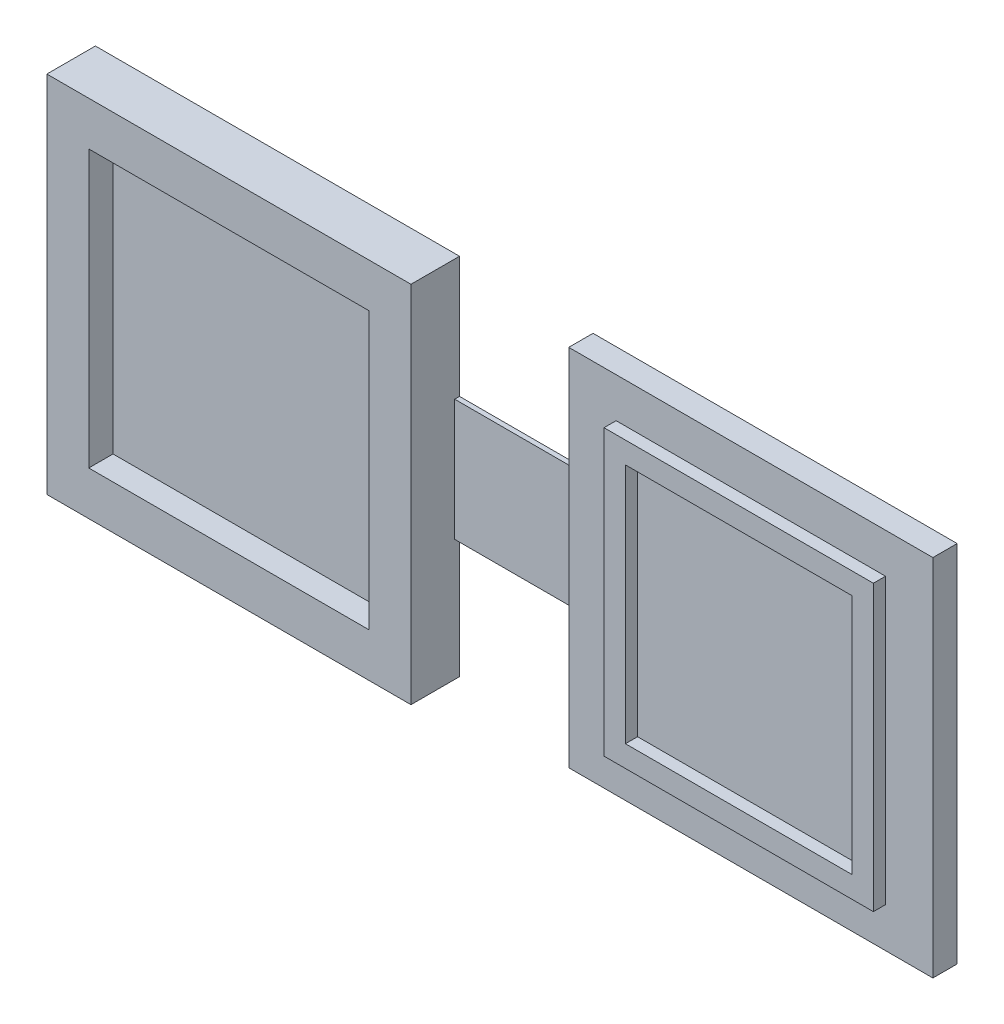
from build123d import *

# Parameters (mm, degrees)
SKETCH1_W             = 30
SKETCH1_H             = 30
BOSS_EXTRUDE1_DEPTH   = 2
BOSS_EXTRUDE1_2_DEPTH = 2
SKETCH1_3_W           = 30
SKETCH1_3_H           = 30
SKETCH1_3_W_2         = 23.094824398
SKETCH1_3_H_2         = 22.76684371
BOSS_EXTRUDE2_DEPTH   = 4
SKETCH1_4_W           = 22.194379656
SKETCH1_4_H           = 23.434004946
SKETCH1_4_W_2         = 18.65884575
SKETCH1_4_H_2         = 19.89847104
BOSS_EXTRUDE3_DEPTH   = 3
SKETCH1_5_W           = 11
SKETCH1_5_H           = 10
BOSS_EXTRUDE4_DEPTH   = 0.4


with BuildPart() as part:
    # Sketch1 → Boss-Extrude1 (new body)
    with BuildSketch(Plane.XY):
        with Locations((-43.876243767, 6.913043478)):
            Rectangle(SKETCH1_W, SKETCH1_H)
    extrude(amount=BOSS_EXTRUDE1_DEPTH)

    # Sketch1_3 → Boss-Extrude2 (add)
    with BuildSketch(Plane.XY):
        with Locations((-43.876243767, 6.913043478)):
            Rectangle(SKETCH1_3_W, SKETCH1_3_H)
        with Locations((-43.876243767, 6.913043478)):
            Rectangle(SKETCH1_3_W_2, SKETCH1_3_H_2, mode=Mode.SUBTRACT)
    extrude(amount=BOSS_EXTRUDE2_DEPTH)



with BuildPart() as body_2:
    # Sketch1 → Boss-Extrude1 2 (new body)
    with BuildSketch(Plane.XY):
        with Locations((-2.876243767, 6.913043478)):
            Rectangle(SKETCH1_W, SKETCH1_H)
    extrude(amount=BOSS_EXTRUDE1_2_DEPTH)

    # Sketch1_4 → Boss-Extrude3 (add)
    with BuildSketch(Plane.XY):
        with Locations((-2.876243767, 6.913043478)):
            Rectangle(SKETCH1_4_W, SKETCH1_4_H)
        with Locations((-2.876243767, 6.913043478)):
            Rectangle(SKETCH1_4_W_2, SKETCH1_4_H_2, mode=Mode.SUBTRACT)
    extrude(amount=BOSS_EXTRUDE3_DEPTH)


with BuildPart() as part_1:
    add(part.part)

    add(body_2.part)  # Boss-Extrude4 merges body 2
    # Sketch1_5 → Boss-Extrude4 (add)
    with BuildSketch(Plane.XY):
        with Locations((-23.376243767, 6.913043478)):
            Rectangle(SKETCH1_5_W, SKETCH1_5_H)
    extrude(amount=BOSS_EXTRUDE4_DEPTH)


solid = part_1.part
